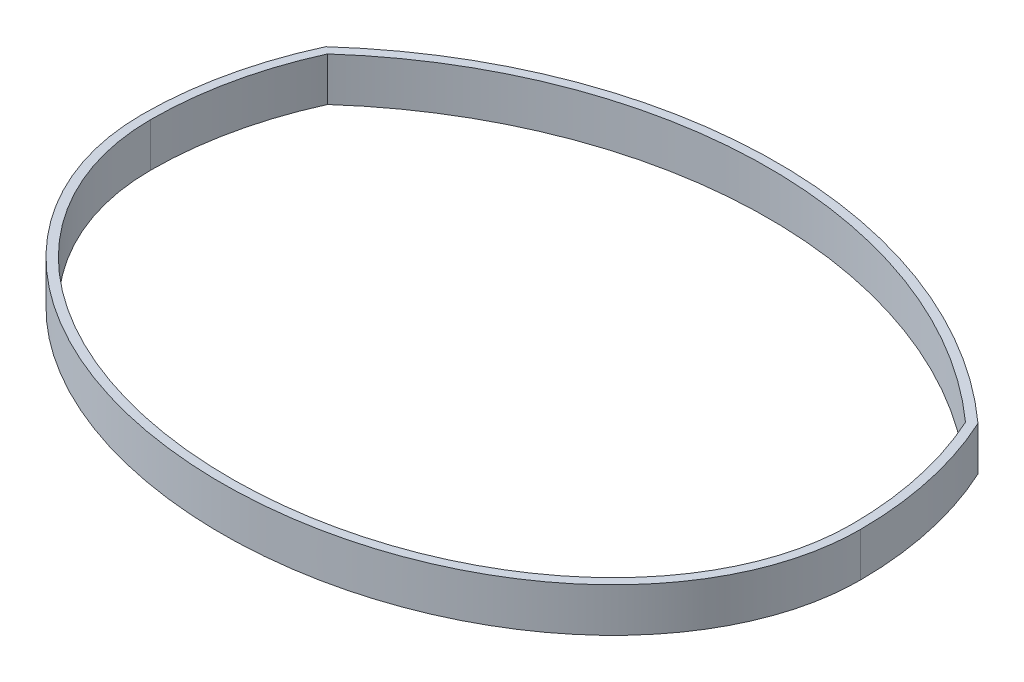
from build123d import *

# Parameters (mm, degrees)
BOSS_EXTRUDE1_DEPTH = 12.7


with BuildPart() as part:
    # Sketch1 → Boss-Extrude1 (new body)
    with BuildSketch(Plane(origin=(0, 0, 0), x_dir=(1, 0, 0), z_dir=(0, 1, 0))):
        with BuildLine():
            ThreePointArc((94.540146528, 43.672649272), (0, 80.034125107), (-94.540146528, 43.672649272))
            ThreePointArc((-94.540146528, 43.672649272), (-101.711726117, 22.357646796), (-104.14, 0))
            add(Edge.make_bspline(
                [(-104.14, 0), (-104.14, -5.353245946), (-102.774000245, -16.038301306), (-96.725381665, -31.419617843), (-86.949494678, -45.523016122), (-69.49958019, -61.933082493), (-40.664381996, -76.791422736), (0, -83.026194763), (40.664381996, -76.791422736), (69.49958019, -61.933082493), (86.949494678, -45.523016122), (96.725381665, -31.419617843), (102.774000245, -16.038301306), (104.14, -5.353245946), (104.14, 0)],
                knots=[0, 0, 0, 0, 0.196349541, 0.392699082, 0.589048623, 0.785398163, 1.178097245, 1.570796327, 1.963495408, 2.35619449, 2.552544031, 2.748893572, 2.945243113, 3.141592654, 3.141592654, 3.141592654, 3.141592654], degree=3))
            ThreePointArc((104.14, 0), (101.711726117, 22.357646796), (94.540146528, 43.672649272))
        make_face()
        with BuildLine():
            ThreePointArc((-92.45080744, 42.135593074), (-99.28635867, 21.558733312), (-101.6, 0))
            add(Edge.make_bspline(
                [(-101.6, 0), (-101.6, -78.407937421), (0, -78.407937421), (101.6, -78.407937421), (101.6, 0)],
                knots=[0, 0, 0, 1.570796327, 1.570796327, 3.141592654, 3.141592654, 3.141592654], degree=2, weights=[1, 0.707106781, 1, 0.707106781, 1]))
            ThreePointArc((101.6, 0), (99.28635867, 21.558733312), (92.45080744, 42.135593074))
            ThreePointArc((92.45080744, 42.135593074), (0, 77.494125107), (-92.45080744, 42.135593074))
        make_face(mode=Mode.SUBTRACT)
    extrude(amount=BOSS_EXTRUDE1_DEPTH)


solid = part.part
